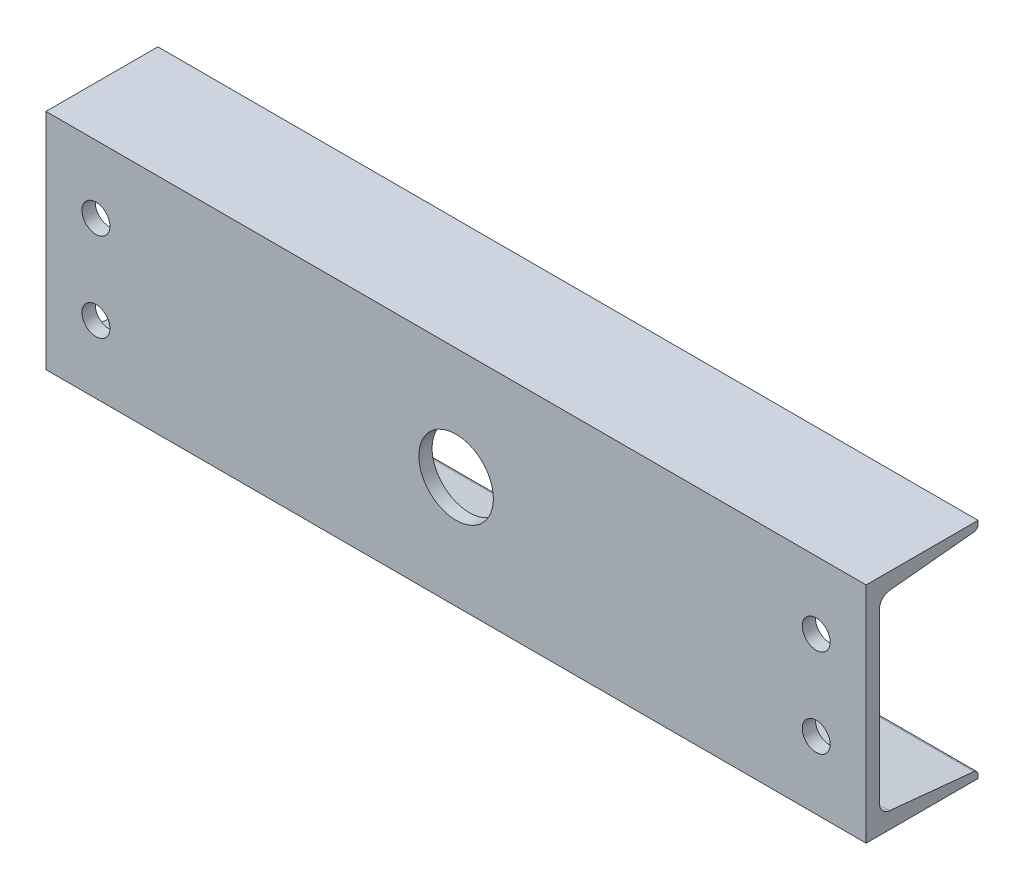
from build123d import *

# Parameters (mm, degrees)
BOSS_EXTRUDE1_DEPTH = 279.4
CUT_EXTRUDE1_REACH  = 78.2
SKETCH2_R           = 25.4
CUT_EXTRUDE2_REACH  = 78.2
SKETCH3_R           = 9.525


with BuildPart() as part:
    # Sketch1 → Boss-Extrude1 (new body, symmetric)
    with BuildSketch(Plane(origin=(0, 0, 0), x_dir=(0, 0, -1), z_dir=(1, 0, 0))):
        with BuildLine():
            Line((-48.8061, -76.2), (-48.8061, 76.2))
            Line((-48.8061, 76.2), (27.3939, 76.2))
            Line((27.3939, 76.2), (27.3939, 73.710744653))
            ThreePointArc((27.3939, 73.710744653), (26.604945151, 71.66452399), (24.646512202, 70.677604975))
            Line((24.646512202, 70.677604975), (-32.895230506, 64.974685943))
            ThreePointArc((-32.895230506, 64.974685943), (-37.791312879, 62.507388407), (-39.7637, 57.391836749))
            Line((-39.7637, 57.391836749), (-39.7637, -57.391836749))
            ThreePointArc((-39.7637, -57.391836749), (-37.791312879, -62.507388407), (-32.895230506, -64.974685943))
            Line((-32.895230506, -64.974685943), (24.646512202, -70.677604975))
            ThreePointArc((24.646512202, -70.677604975), (26.604945151, -71.66452399), (27.3939, -73.710744653))
            Line((27.3939, -73.710744653), (27.3939, -76.2))
            Line((27.3939, -76.2), (-48.8061, -76.2))
        make_face()
    extrude(amount=BOSS_EXTRUDE1_DEPTH, both=True)

    # Sketch2 → Cut-Extrude1 (cut, up to next)
    with BuildSketch(Plane.XY.offset(48.8061), mode=Mode.PRIVATE) as cut_extrude1_sk1:
        Circle(SKETCH2_R)
    cut_extrude1_tool1 = extrude(cut_extrude1_sk1.sketch, amount=-CUT_EXTRUDE1_REACH, mode=Mode.PRIVATE) & part.part
    add(cut_extrude1_tool1.solids().sort_by_distance((0, 0, 48.8061))[0], mode=Mode.SUBTRACT)

    # Sketch3 → Cut-Extrude2 (cut, up to next)
    with BuildSketch(Plane.XY.offset(48.8061), mode=Mode.PRIVATE) as cut_extrude2_sk1:
        with Locations((-245.364, 30.1625)):
            Circle(SKETCH3_R)
    cut_extrude2_tool1 = extrude(cut_extrude2_sk1.sketch, amount=-CUT_EXTRUDE2_REACH, mode=Mode.PRIVATE) & part.part
    add(cut_extrude2_tool1.solids().sort_by_distance((-245.364, 30.1625, 48.8061))[0], mode=Mode.SUBTRACT)
    # Sketch3 → Cut-Extrude2 (cut, up to next)
    with BuildSketch(Plane.XY.offset(48.8061), mode=Mode.PRIVATE) as cut_extrude2_sk2:
        with Locations((245.364, 30.1625)):
            Circle(SKETCH3_R)
    cut_extrude2_tool2 = extrude(cut_extrude2_sk2.sketch, amount=-CUT_EXTRUDE2_REACH, mode=Mode.PRIVATE) & part.part
    add(cut_extrude2_tool2.solids().sort_by_distance((245.364, 30.1625, 48.8061))[0], mode=Mode.SUBTRACT)
    # Sketch3 → Cut-Extrude2 (cut, up to next)
    with BuildSketch(Plane.XY.offset(48.8061), mode=Mode.PRIVATE) as cut_extrude2_sk3:
        with Locations((245.364, -30.1625)):
            Circle(SKETCH3_R)
    cut_extrude2_tool3 = extrude(cut_extrude2_sk3.sketch, amount=-CUT_EXTRUDE2_REACH, mode=Mode.PRIVATE) & part.part
    add(cut_extrude2_tool3.solids().sort_by_distance((245.364, -30.1625, 48.8061))[0], mode=Mode.SUBTRACT)
    # Sketch3 → Cut-Extrude2 (cut, up to next)
    with BuildSketch(Plane.XY.offset(48.8061), mode=Mode.PRIVATE) as cut_extrude2_sk4:
        with Locations((-245.364, -30.1625)):
            Circle(SKETCH3_R)
    cut_extrude2_tool4 = extrude(cut_extrude2_sk4.sketch, amount=-CUT_EXTRUDE2_REACH, mode=Mode.PRIVATE) & part.part
    add(cut_extrude2_tool4.solids().sort_by_distance((-245.364, -30.1625, 48.8061))[0], mode=Mode.SUBTRACT)


solid = part.part
